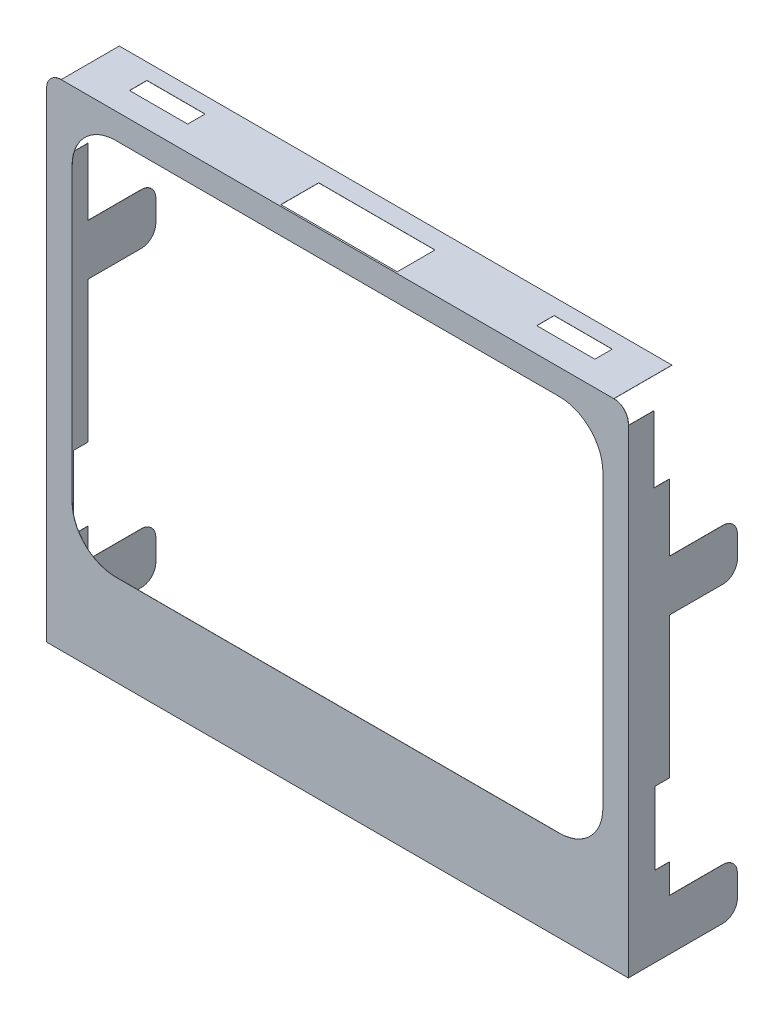
from build123d import *

# Parameters (mm, degrees)
RESSALTO_EXTRUS_O1_DEPTH = 0.01
ESBO_O2_W                = 5.5
ESBO_O2_H                = 1
RESSALTO_EXTRUS_O2_DEPTH = 0.01
RESSALTO_EXTRUS_O3_DEPTH = 0.01
RESSALTO_EXTRUS_O6_DEPTH = 0.01
ESBO_O5_W                = 38
ESBO_O5_H                = 4
ESBO_O5_W_2              = 8
ESBO_O5_H_2              = 2.6
ESBO_O5_W_3              = 4
ESBO_O5_H_3              = 1.2
RESSALTO_EXTRUS_O8_DEPTH = 0.01


with BuildPart() as part:
    # Esboço1 → Ressalto-extrusão1 (new body)
    with BuildSketch(Plane.XY):
        with BuildLine():
            Line((0, 0), (40, 0))
            Line((40, 0), (40, 33))
            ThreePointArc((40, 33), (39.707106781, 33.707106781), (39, 34))
            Line((39, 34), (1, 34))
            ThreePointArc((1, 34), (0.292893219, 33.707106781), (0, 33))
            Line((0, 33), (0, 0))
        make_face()
        with BuildLine():
            Line((4.75, 6.25), (35.25, 6.25))
            ThreePointArc((35.25, 6.25), (37.371320344, 7.128679656), (38.25, 9.25))
            Line((38.25, 9.25), (38.25, 29.25))
            ThreePointArc((38.25, 29.25), (37.371320344, 31.371320344), (35.25, 32.25))
            Line((35.25, 32.25), (4.75, 32.25))
            ThreePointArc((4.75, 32.25), (2.628679656, 31.371320344), (1.75, 29.25))
            Line((1.75, 29.25), (1.75, 9.25))
            ThreePointArc((1.75, 9.25), (2.628679656, 7.128679656), (4.75, 6.25))
        make_face(mode=Mode.SUBTRACT)
    extrude(amount=RESSALTO_EXTRUS_O1_DEPTH)

    # Esboço2 → Ressalto-extrusão2 (add)
    with BuildSketch(Plane.XZ):
        Polygon((1, -3.99), (3, -3.99), (3, -2.832105263), (12, -2.832105263), (12, -3.99), (39, -3.99), (39, 0.01), (1, 0.01), align=None)
        with Locations((20, -1.99)):
            Rectangle(ESBO_O2_W, ESBO_O2_H, mode=Mode.SUBTRACT)
    extrude(amount=-RESSALTO_EXTRUS_O2_DEPTH)

    # Esboço3 → Ressalto-extrusão3 (add)
    with BuildSketch(Plane(origin=(40, 0, 0), x_dir=(0, 0, -1), z_dir=(1, 0, 0))):
        with BuildLine():
            Line((4.5527289, 3.5), (2.83, 3.5))
            Line((2.83, 3.5), (2.83, 5.5))
            Line((2.83, 5.5), (1.83, 5.5))
            Line((1.83, 5.5), (1.83, 10.5))
            Line((1.83, 10.5), (2.83, 10.5))
            Line((2.83, 10.5), (2.83, 20.2))
            Line((2.83, 20.2), (6.49, 20.2))
            ThreePointArc((6.49, 20.2), (7.197106781, 20.492893219), (7.49, 21.2))
            Line((7.49, 21.2), (7.49, 22.7))
            ThreePointArc((7.49, 22.7), (7.197106781, 23.407106781), (6.49, 23.7))
            Line((6.49, 23.7), (2.83, 23.7))
            Line((2.83, 23.7), (2.83, 28.3))
            Line((2.83, 28.3), (1.743518889, 28.3))
            Line((1.743518889, 28.3), (1.743518889, 32.9))
            Line((1.743518889, 32.9), (-0.01, 32.9))
            Line((-0.01, 32.9), (-0.01, 0))
            Line((-0.01, 0), (3.99, 0))
            Line((3.99, 0), (6.49, 0))
            ThreePointArc((6.49, 0), (7.197106781, 0.292893219), (7.49, 1))
            Line((7.49, 1), (7.49, 2.5))
            ThreePointArc((7.49, 2.5), (7.197106781, 3.207106781), (6.49, 3.5))
            Line((6.49, 3.5), (4.5527289, 3.5))
        make_face()
    extrude(amount=-RESSALTO_EXTRUS_O3_DEPTH)

    # Esboço5 → Ressalto-extrusão8 (add)
    with BuildSketch(Plane(origin=(0, 34, 0), x_dir=(1, 0, 0), z_dir=(0, 1, 0))):
        with Locations((20, 1.99)):
            Rectangle(ESBO_O5_W, ESBO_O5_H)
        with Locations((20, 1.4)):
            Rectangle(ESBO_O5_W_2, ESBO_O5_H_2, mode=Mode.SUBTRACT)
        with Locations((34, 2.29)):
            Rectangle(ESBO_O5_W_3, ESBO_O5_H_3, mode=Mode.SUBTRACT)
        with Locations((6, 2.29)):
            Rectangle(ESBO_O5_W_3, ESBO_O5_H_3, mode=Mode.SUBTRACT)
    extrude(amount=-RESSALTO_EXTRUS_O8_DEPTH)


with BuildPart() as body_2:
    # Esboço4 → Ressalto-extrusão6 (new body)
    with BuildSketch(Plane.ZY):
        with BuildLine():
            Line((-6.49, 0), (0, 0))
            Line((0, 0), (0, 32.9))
            Line((0, 32.9), (-1.743518889, 32.9))
            Line((-1.743518889, 32.9), (-1.743518889, 28.3))
            Line((-1.743518889, 28.3), (-2.83, 28.3))
            Line((-2.83, 28.3), (-2.83, 23.7))
            Line((-2.83, 23.7), (-6.49, 23.7))
            ThreePointArc((-6.49, 23.7), (-7.197106781, 23.407106781), (-7.49, 22.7))
            Line((-7.49, 22.7), (-7.49, 21.2))
            ThreePointArc((-7.49, 21.2), (-7.197106781, 20.492893219), (-6.49, 20.2))
            Line((-6.49, 20.2), (-2.83, 20.2))
            Line((-2.83, 20.2), (-2.83, 10.5))
            Line((-2.83, 10.5), (-1.83, 10.5))
            Line((-1.83, 10.5), (-1.83, 5.5))
            Line((-1.83, 5.5), (-2.83, 5.5))
            Line((-2.83, 5.5), (-2.83, 3.5))
            Line((-2.83, 3.5), (-6.49, 3.5))
            ThreePointArc((-6.49, 3.5), (-7.197106781, 3.207106781), (-7.49, 2.5))
            Line((-7.49, 2.5), (-7.49, 1))
            ThreePointArc((-7.49, 1), (-7.197106781, 0.292893219), (-6.49, 0))
        make_face()
    extrude(amount=-RESSALTO_EXTRUS_O6_DEPTH)

    # Combinar2: union part
    add(part.part)


solid = body_2.part
